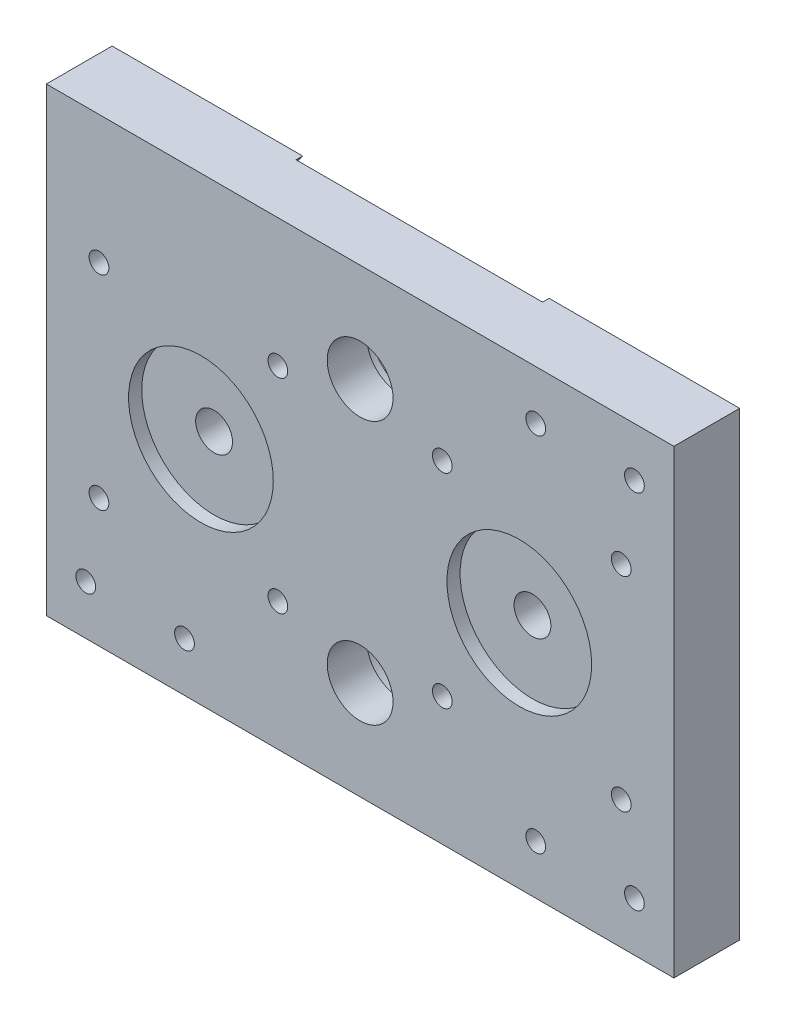
from build123d import *

# Parameters (mm, degrees)
SKETCH1_W           = 25
SKETCH1_H           = 70
SKETCH1_R           = 7.9375
BOSS_EXTRUDE1_DEPTH = 10
SKETCH2_R           = 1.5
SKETCH2_R_2         = 2.8
BOSS_EXTRUDE2_DEPTH = 10
SKETCH6_R           = 1.5
CUT_EXTRUDE3_DEPTH  = 10
SKETCH3_R           = 7.9375
SKETCH3_R_2         = 5
BOSS_EXTRUDE3_DEPTH = 6.0216
SKETCH4_R           = 11
CUT_EXTRUDE1_DEPTH  = 2
SKETCH5_R           = 2.75
CUT_EXTRUDE2_DEPTH  = 3.1
SKETCH11_R          = 10.2
CUT_EXTRUDE6_DEPTH  = 2
SKETCH12_R          = 12.5
CUT_EXTRUDE8_DEPTH  = 2
SKETCH13_R          = 1.5
CUT_EXTRUDE9_DEPTH  = 10
SKETCH14_R          = 24
CUT_EXTRUDE10_DEPTH = 1


with BuildPart() as part:
    # Sketch1 → Boss-Extrude1 (new body)
    with BuildSketch(Plane.XY):
        with Locations((0, 20)):
            Rectangle(SKETCH1_W, SKETCH1_H)
        with Locations((0, 40)):
            Circle(SKETCH1_R, mode=Mode.SUBTRACT)
        Circle(SKETCH1_R, mode=Mode.SUBTRACT)
    extrude(amount=BOSS_EXTRUDE1_DEPTH)

    # Sketch2 → Boss-Extrude2 (add)
    with BuildSketch(Plane.XY.offset(10)):
        with BuildLine():
            Line((-47.7, 55), (-8.2, 55))
            Line((-8.2, 55), (-8.2, 36.914213562))
            ThreePointArc((-8.2, 36.914213562), (-10.2, 35.5), (-8.2, 34.085786438))
            Line((-8.2, 34.085786438), (-8.2, 5.914213562))
            ThreePointArc((-8.2, 5.914213562), (-10.2, 4.5), (-8.2, 3.085786438))
            Line((-8.2, 3.085786438), (-8.2, -15))
            Line((-8.2, -15), (-47.7, -15))
            Line((-47.7, -15), (-47.7, 55))
        make_face()
        with Locations((-39.7, 35.5)):
            Circle(SKETCH2_R, mode=Mode.SUBTRACT)
        with Locations((-39.7, 4.5)):
            Circle(SKETCH2_R, mode=Mode.SUBTRACT)
        with Locations((-24.2, 20)):
            Circle(SKETCH2_R_2, mode=Mode.SUBTRACT)
        with BuildLine():
            Line((8.2, 55), (8.2, 36.914213562))
            ThreePointArc((8.2, 36.914213562), (10.2, 35.5), (8.2, 34.085786438))
            Line((8.2, 34.085786438), (8.2, 5.914213562))
            ThreePointArc((8.2, 5.914213562), (10.2, 4.5), (8.2, 3.085786438))
            Line((8.2, 3.085786438), (8.2, -15))
            Line((8.2, -15), (47.7, -15))
            Line((47.7, -15), (47.7, 55))
            Line((47.7, 55), (8.2, 55))
        make_face()
        with Locations((39.7, 4.5)):
            Circle(SKETCH2_R, mode=Mode.SUBTRACT)
        with Locations((39.7, 35.5)):
            Circle(SKETCH2_R, mode=Mode.SUBTRACT)
        with Locations((24.2, 20)):
            Circle(SKETCH2_R_2, mode=Mode.SUBTRACT)
    extrude(amount=-BOSS_EXTRUDE2_DEPTH)

    # Sketch6 → Cut-Extrude3 (cut)
    with BuildSketch(Plane.XY.offset(10)):
        with Locations((-12.5, 35.5)):
            Circle(SKETCH6_R)
        with Locations((12.5, 35.5)):
            Circle(SKETCH6_R)
        with Locations((-12.5, 4.5)):
            Circle(SKETCH6_R)
        with Locations((12.5, 4.5)):
            Circle(SKETCH6_R)
    extrude(amount=-CUT_EXTRUDE3_DEPTH, mode=Mode.SUBTRACT)

    # Sketch3 → Boss-Extrude3 (add)
    with BuildSketch(Plane.XY.offset(10)):
        with Locations((0, 40)):
            Circle(SKETCH3_R)
        with Locations((0, 40)):
            Circle(SKETCH3_R_2, mode=Mode.SUBTRACT)
        Circle(SKETCH3_R)
        Circle(SKETCH3_R_2, mode=Mode.SUBTRACT)
    extrude(amount=-BOSS_EXTRUDE3_DEPTH)

    # Sketch4 → Cut-Extrude1 (cut)
    with BuildSketch(Plane.XY.offset(10)):
        with Locations((-24.2, 20)):
            Circle(SKETCH4_R)
        with Locations((24.2, 20)):
            Circle(SKETCH4_R)
    extrude(amount=-CUT_EXTRUDE1_DEPTH, mode=Mode.SUBTRACT)

    # Sketch5 → Cut-Extrude2 (cut)
    with BuildSketch(Plane(origin=(0, 0, 0), x_dir=(-1, 0, 0), z_dir=(0, 0, -1))):
        with Locations((-39.7, 35.5)):
            Circle(SKETCH5_R)
        with Locations((-12.5, 35.5)):
            Circle(SKETCH5_R)
        with Locations((-39.7, 4.5)):
            Circle(SKETCH5_R)
        with Locations((-12.5, 4.5)):
            Circle(SKETCH5_R)
        with Locations((12.5, 35.5)):
            Circle(SKETCH5_R)
        with Locations((39.7, 35.5)):
            Circle(SKETCH5_R)
        with Locations((12.5, 4.5)):
            Circle(SKETCH5_R)
        with Locations((39.7, 4.5)):
            Circle(SKETCH5_R)
    extrude(amount=-CUT_EXTRUDE2_DEPTH, mode=Mode.SUBTRACT)

    # Sketch11 → Cut-Extrude6 (cut)
    with BuildSketch(Plane(origin=(0, 0, 0), x_dir=(-1, 0, 0), z_dir=(0, 0, -1))):
        with Locations((-24.2, 20)):
            Circle(SKETCH11_R)
        with Locations((24.2, 20)):
            Circle(SKETCH11_R)
    extrude(amount=-CUT_EXTRUDE6_DEPTH, mode=Mode.SUBTRACT)

    # Sketch12 → Cut-Extrude8 (cut)
    with BuildSketch(Plane(origin=(0, 0, 0), x_dir=(-1, 0, 0), z_dir=(0, 0, -1))):
        with Locations((24.2, 20)):
            Circle(SKETCH12_R)
    extrude(amount=-CUT_EXTRUDE8_DEPTH, mode=Mode.SUBTRACT)

    # Sketch13 → Cut-Extrude9 (cut)
    with BuildSketch(Plane.XY.offset(10)):
        with Locations((-41.7, -7.5)):
            Circle(SKETCH13_R)
        with Locations((-26.7, -7.5)):
            Circle(SKETCH13_R)
        with Locations((26.7, -7.5)):
            Circle(SKETCH13_R)
        with Locations((41.7, -7.5)):
            Circle(SKETCH13_R)
        with Locations((26.7, 47.5)):
            Circle(SKETCH13_R)
        with Locations((41.7, 47.5)):
            Circle(SKETCH13_R)
    extrude(amount=-CUT_EXTRUDE9_DEPTH, mode=Mode.SUBTRACT)

    # Sketch14 → Cut-Extrude10 (cut)
    with BuildSketch(Plane(origin=(0, 0, 0), x_dir=(-1, 0, 0), z_dir=(0, 0, -1))):
        with Locations((0, 40)):
            Circle(SKETCH14_R)
    extrude(amount=-CUT_EXTRUDE10_DEPTH, mode=Mode.SUBTRACT)


solid = part.part
